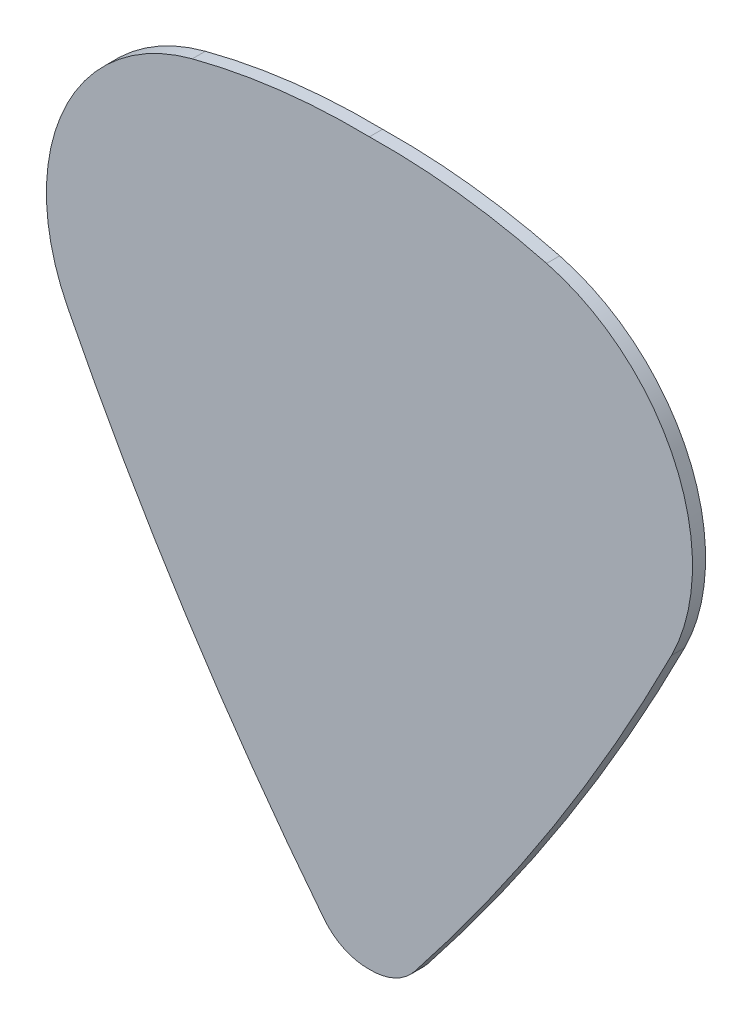
from build123d import *

# Parameters (mm, degrees)
BOSS_EXTRUDE2_DEPTH = 0.6


with BuildPart() as part:
    # Sketch2 → Boss-Extrude2 (new body)
    with BuildSketch(Plane.XY):
        with BuildLine():
            ThreePointArc((2.074223627, -15.871495922), (1.151683238, -16.599881603), (0, -16.834939442))
            ThreePointArc((0, -16.834939442), (-1.151683238, -16.599881603), (-2.074223627, -15.871495922))
            ThreePointArc((-2.074223627, -15.871495922), (-8.410066736, -6.972099792), (-13.820679581, 2.518286292))
            ThreePointArc((-13.820679581, 2.518286292), (-13.991707448, 10.221670001), (-8.106427403, 15.195084311))
            ThreePointArc((-8.106427403, 15.195084311), (-4.08641149, 15.955883205), (0, 16.157338))
            ThreePointArc((0, 16.157338), (4.08641149, 15.955883205), (8.106427403, 15.195084311))
            ThreePointArc((8.106427403, 15.195084311), (13.991707448, 10.221670001), (13.820679581, 2.518286292))
            ThreePointArc((13.820679581, 2.518286292), (8.410066736, -6.972099792), (2.074223627, -15.871495922))
        make_face()
    extrude(amount=BOSS_EXTRUDE2_DEPTH)


solid = part.part
